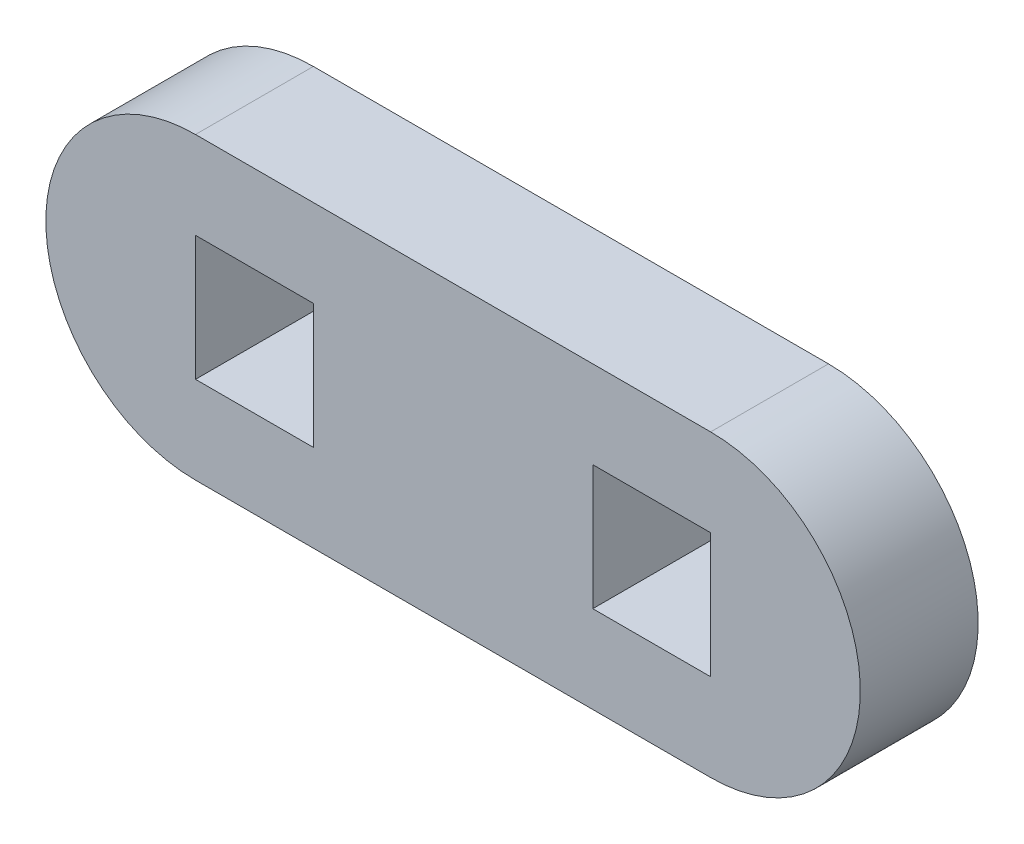
from build123d import *

# Parameters (mm, degrees)
SKETCH2_W           = 6
SKETCH2_H           = 6.35
BOSS_EXTRUDE1_DEPTH = 6


with BuildPart() as part:
    # Sketch2 → Boss-Extrude1 (new body)
    with BuildSketch(Plane.XY):
        with BuildLine():
            Line((297.889925989, 61.9894), (324.113925989, 61.9894))
            ThreePointArc((324.113925989, 61.9894), (331.733925989, 54.3694), (324.113925989, 46.7494))
            Line((324.113925989, 46.7494), (297.889925989, 46.7494))
            ThreePointArc((297.889925989, 46.7494), (290.269925989, 54.3694), (297.889925989, 61.9894))
        make_face()
        with Locations((300.889925989, 54.3694)):
            Rectangle(SKETCH2_W, SKETCH2_H, mode=Mode.SUBTRACT)
        with Locations((321.113925989, 54.3694)):
            Rectangle(SKETCH2_W, SKETCH2_H, mode=Mode.SUBTRACT)
    extrude(amount=BOSS_EXTRUDE1_DEPTH)


solid = part.part
